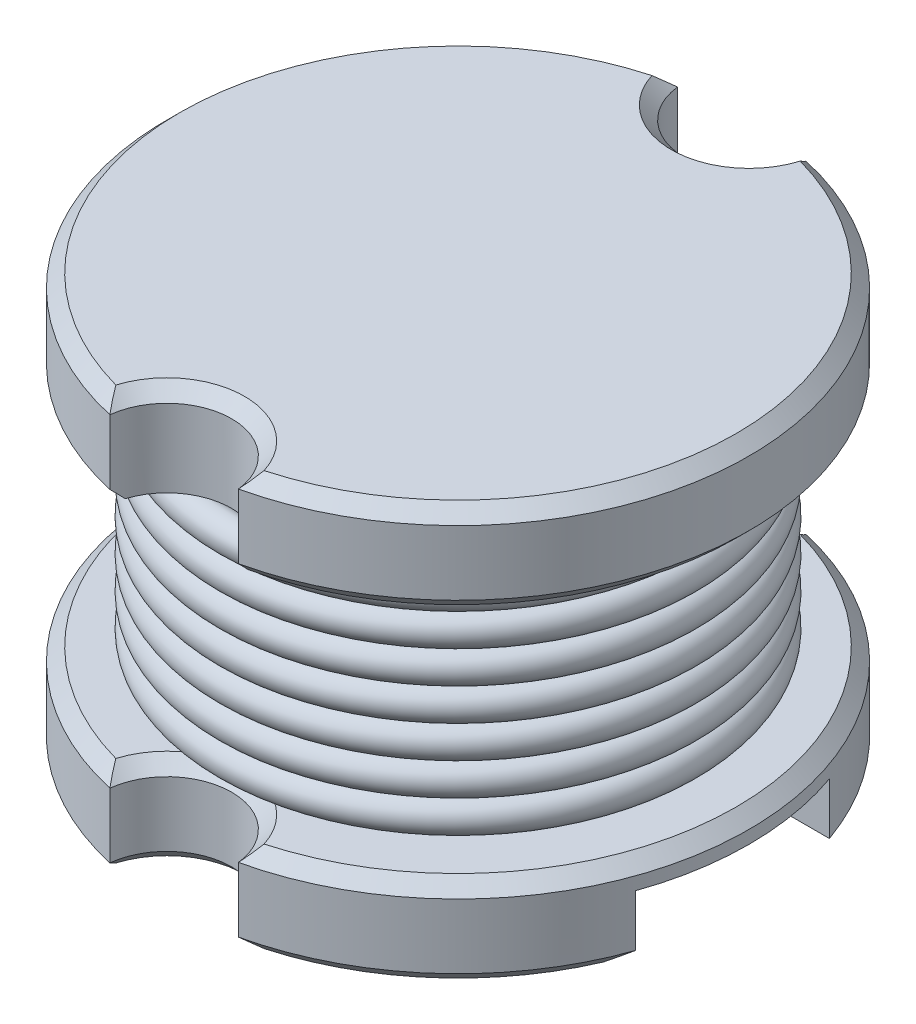
from build123d import *

# Parameters (mm, degrees)
SKETCH1_R           = 2.25
BOSS_EXTRUDE1_DEPTH = 0.7
SKETCH2_R           = 1.5
BOSS_EXTRUDE2_DEPTH = 1.8
SKETCH3_R           = 2.25
BOSS_EXTRUDE3_DEPTH = 0.7
SKETCH5_R           = 0.5
CUT_EXTRUDE2_DEPTH  = 3.2
SWEEP1_PROFILE_R    = 0.125
LPATTERN4_COUNT     = 7
LPATTERN4_PITCH     = 0.25
SKETCH87_W          = 10.580521724
SKETCH87_H          = 1.5
CUT_EXTRUDE3_DEPTH  = 0.5
CHAMFER1_SIZE       = 0.1


with BuildPart() as part:
    # Sketch1 → Boss-Extrude1 (new body)
    with BuildSketch(Plane(origin=(0, 0, 0), x_dir=(1, 0, 0), z_dir=(0, 1, 0))):
        Circle(SKETCH1_R)
    extrude(amount=BOSS_EXTRUDE1_DEPTH)

    # Sketch2 → Boss-Extrude2 (add)
    with BuildSketch(Plane(origin=(0, 0.7, 0), x_dir=(1, 0, 0), z_dir=(0, 1, 0))):
        Circle(SKETCH2_R)
    extrude(amount=BOSS_EXTRUDE2_DEPTH)

    # Sketch3 → Boss-Extrude3 (add)
    with BuildSketch(Plane(origin=(0, 2.5, 0), x_dir=(1, 0, 0), z_dir=(0, 1, 0))):
        Circle(SKETCH3_R)
    extrude(amount=BOSS_EXTRUDE3_DEPTH)

    # Sketch5 → Cut-Extrude2 (cut)
    with BuildSketch(Plane(origin=(0, 3.2, 0), x_dir=(1, 0, 0), z_dir=(0, 1, 0))):
        with Locations((0, -2.25)):
            Circle(SKETCH5_R)
        with Locations((0, 2.25)):
            Circle(SKETCH5_R)
    extrude(amount=-CUT_EXTRUDE2_DEPTH, mode=Mode.SUBTRACT)

    # Sketch87 → Cut-Extrude3 (cut)
    with BuildSketch(Plane.XZ):
        Rectangle(SKETCH87_W, SKETCH87_H)
    extrude(amount=-CUT_EXTRUDE3_DEPTH, mode=Mode.SUBTRACT)

    # Chamfer1
    chamfer1_edges = [part.edges().sort_by_distance(p)[0] for p in [
        (1.495118594, 0, 1.681404291),
        (0, 0, 1.75),
        (0, 3.2, 1.75),
        (0, 0.7, 1.75),
        (-2.25, 2.5, 0),
        (-2.25, 3.2, 0),
        (-1.495118594, 0, -1.681404291),
        (-2.25, 0.7, 0),
        (0, 0, -1.75),
        (0, 3.2, -1.75),
        (0, 0.7, -1.75),
        (2.25, 0.7, 0),
        (-1.495118594, 0, 1.681404291),
        (1.495118594, 0, -1.681404291),
        (0, 0, -0.75),
        (0, 0, 0.75),
        (-1.5, 0.7, 0),
        (2.25, 2.5, 0),
        (2.25, 3.2, 0),
    ]]
    chamfer(chamfer1_edges, length=CHAMFER1_SIZE)


with BuildPart() as body_2:
    # Sweep1: sweep along a path in Sketch6
    with BuildLine(Plane(origin=(0, 0.825, 0), x_dir=(1, 0, 0), z_dir=(0, 1, 0))) as sweep1_path:
        CenterArc((0, 0), 1.75, 0, 360)
    # Sweep1 profile (on start of the path) → Sweep1 (sweep)
    with BuildSketch(Plane(origin=(1.75, 0.825, 0), x_dir=(-1, 0, 0), z_dir=(0, 0, -1))):
        Circle(SWEEP1_PROFILE_R)
    sweep(path=sweep1_path.line)


with BuildPart() as lpattern4_1:
    # LPattern4: pattern copy
    add(body_2.part.moved(Location(Vector(0, 1, 0) * (1 * LPATTERN4_PITCH))))


with BuildPart() as lpattern4_2:
    # LPattern4: pattern copy
    add(body_2.part.moved(Location(Vector(0, 1, 0) * (2 * LPATTERN4_PITCH))))


with BuildPart() as lpattern4_3:
    # LPattern4: pattern copy
    add(body_2.part.moved(Location(Vector(0, 1, 0) * (3 * LPATTERN4_PITCH))))


with BuildPart() as lpattern4_4:
    # LPattern4: pattern copy
    add(body_2.part.moved(Location(Vector(0, 1, 0) * (4 * LPATTERN4_PITCH))))


with BuildPart() as lpattern4_5:
    # LPattern4: pattern copy
    add(body_2.part.moved(Location(Vector(0, 1, 0) * (5 * LPATTERN4_PITCH))))


with BuildPart() as lpattern4_6:
    # LPattern4: pattern copy
    add(body_2.part.moved(Location(Vector(0, 1, 0) * (6 * LPATTERN4_PITCH))))


solid = Compound([part.part, body_2.part, lpattern4_1.part, lpattern4_2.part, lpattern4_3.part, lpattern4_4.part, lpattern4_5.part, lpattern4_6.part])
